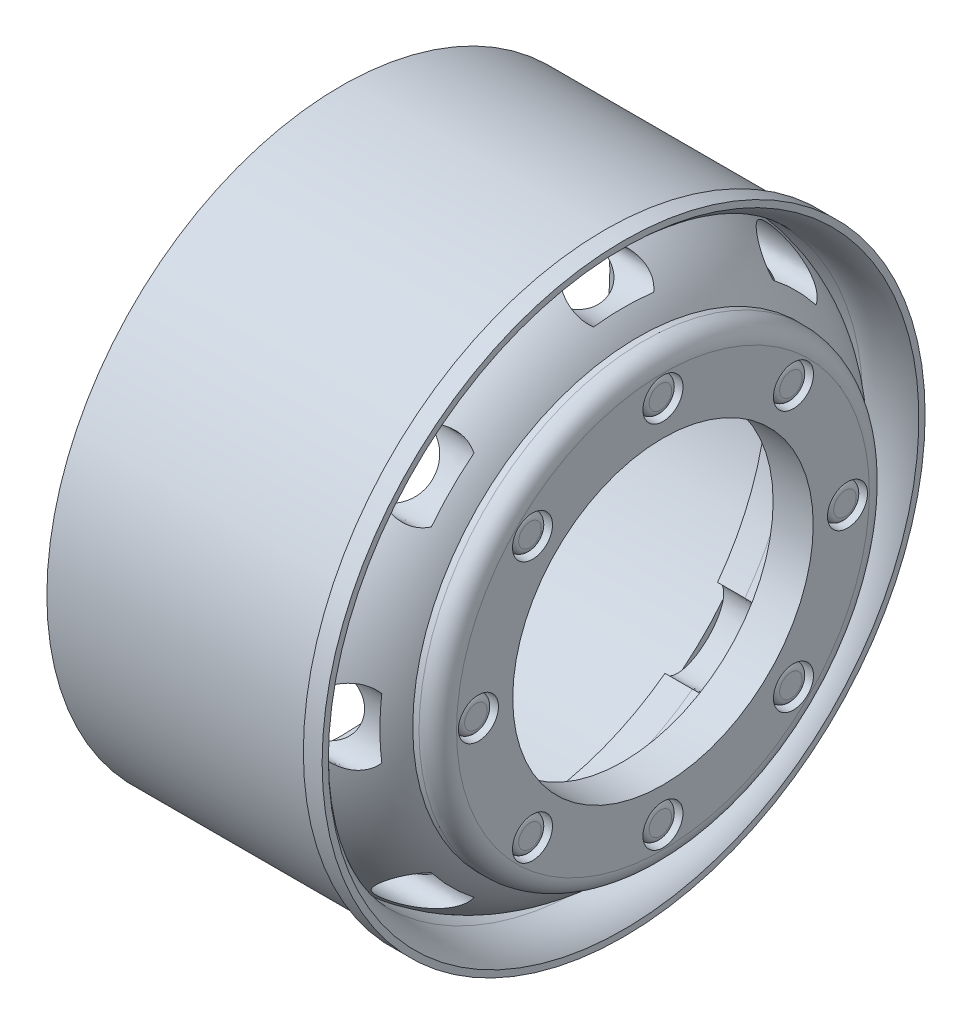
from build123d import *

# Parameters (mm, degrees)
SKETCH3_RX          = 3
SKETCH3_RY          = 1.666666667
CUT_EXTRUDE2_DEPTH  = 8.793413
CIRPATTERN1_COUNT   = 8
SKETCH5_R           = 1.6
CUT_EXTRUDE3_DEPTH  = 1.703824
SKETCH6_R           = 1.4
BOSS_EXTRUDE1_DEPTH = 1.5
FILLET1_R           = 0.5
SKETCH7_R           = 12.008791447
CUT_EXTRUDE4_DEPTH  = 26.745811191
FILLET2_R           = 1.5


with BuildPart() as part:
    # Sketch1 → Revolve1 (revolve)
    with BuildSketch(Plane.XY):
        with BuildLine():
            Line((-10, 23.5), (11.1, 23.5))
            Line((11.1, 23.5), (11.1, 24.1))
            Line((11.1, 24.1), (12.6, 24.1))
            Line((12.6, 24.1), (12.6, 23.6))
            ThreePointArc((12.6, 23.6), (11.157412974, 22.597075431), (9.425748686, 22.3))
            Line((9.425748686, 22.3), (6, 22.3))
            ThreePointArc((6, 22.3), (10.429661133, 21.152912389), (13.745811191, 18))
            Line((13.745811191, 18), (15.745811191, 18))
            Line((15.745811191, 18), (15.745811191, 8.483712034))
            Line((15.745811191, 8.483712034), (12.541986778, 8.483712034))
            Line((12.541986778, 8.483712034), (12.541986778, 16))
            ThreePointArc((12.541986778, 16), (9.914319577, 19.128751492), (6, 20.3))
            Line((6, 20.3), (3.806587083, 20.3))
            Line((3.806587083, 20.3), (3.806587083, 21.5))
            Line((3.806587083, 21.5), (-10, 21.5))
            Line((-10, 21.5), (-10, 23.5))
        make_face()
    revolve(axis=Axis((-25, 0, 0), (1, 0, 0)))

    # Sketch3 → Cut-Extrude2 (cut)
    with BuildSketch(Plane(origin=(12.6, 0, 0), x_dir=(0, 0, -1), z_dir=(1, 0, 0))):
        with Locations((0, 20.323082194)):
            Ellipse(SKETCH3_RX, SKETCH3_RY)
    cut_extrude2 = extrude(amount=-CUT_EXTRUDE2_DEPTH, mode=Mode.SUBTRACT)

    # CirPattern1: Cut-Extrude2 ×8 about axis
    cirpattern1_axis = Axis((15.745811191, 0, 0), (-1, 0, 0))
    for i in range(1, CIRPATTERN1_COUNT):
        add(cut_extrude2.rotate(cirpattern1_axis, i * 360 / CIRPATTERN1_COUNT), mode=Mode.SUBTRACT)

    # Sketch5 → Cut-Extrude3 (cut)
    with BuildSketch(Plane(origin=(15.745811191, 0, 0), x_dir=(0, 0, -1), z_dir=(1, 0, 0))):
        with Locations((0, 14.75)):
            Circle(SKETCH5_R)
        with Locations((10.429825023, 10.429825023)):
            Circle(SKETCH5_R)
        with Locations((14.75, 0)):
            Circle(SKETCH5_R)
        with Locations((10.429825023, -10.429825023)):
            Circle(SKETCH5_R)
        with Locations((0, -14.75)):
            Circle(SKETCH5_R)
        with Locations((-10.429825023, -10.429825023)):
            Circle(SKETCH5_R)
        with Locations((-14.75, 0)):
            Circle(SKETCH5_R)
        with Locations((-10.429825023, 10.429825023)):
            Circle(SKETCH5_R)
    extrude(amount=-CUT_EXTRUDE3_DEPTH, mode=Mode.SUBTRACT)

    # Sketch6 → Boss-Extrude1 (add)
    with BuildSketch(Plane(origin=(14.041986778, 0, 0), x_dir=(0, 0, -1), z_dir=(1, 0, 0))):
        with Locations((-14.75, 0)):
            Circle(SKETCH6_R)
        with Locations((-10.429825023, 10.429825023)):
            Circle(SKETCH6_R)
        with Locations((0, 14.75)):
            Circle(SKETCH6_R)
        with Locations((10.429825023, 10.429825023)):
            Circle(SKETCH6_R)
        with Locations((14.75, 0)):
            Circle(SKETCH6_R)
        with Locations((10.429825023, -10.429825023)):
            Circle(SKETCH6_R)
        with Locations((0, -14.75)):
            Circle(SKETCH6_R)
        with Locations((-10.429825023, -10.429825023)):
            Circle(SKETCH6_R)
    extrude(amount=BOSS_EXTRUDE1_DEPTH)

    # Fillet1
    fillet1_edges = [part.edges().sort_by_distance(p)[0] for p in [
        (15.541986778, 0, 16.15),
        (15.541986778, 10.429825023, 11.829825023),
        (15.541986778, 14.75, 1.4),
        (15.541986778, 10.429825023, -9.029825023),
        (15.541986778, 0, -13.35),
        (15.541986778, -10.429825023, -9.029825023),
        (15.541986778, -14.75, 1.4),
        (15.541986778, -10.429825023, 11.829825023),
    ]]
    fillet(fillet1_edges, radius=FILLET1_R)

    # Sketch7 → Cut-Extrude4 (cut, through all)
    with BuildSketch(Plane(origin=(15.745811191, 0, 0), x_dir=(0, 0, -1), z_dir=(1, 0, 0))):
        Circle(SKETCH7_R)
    extrude(amount=-CUT_EXTRUDE4_DEPTH, mode=Mode.SUBTRACT)

    # Fillet2
    fillet2_edges = [part.edges().sort_by_distance(p)[0] for p in [
        (15.745811191, -18, 0),
    ]]
    fillet(fillet2_edges, radius=FILLET2_R)


solid = part.part
